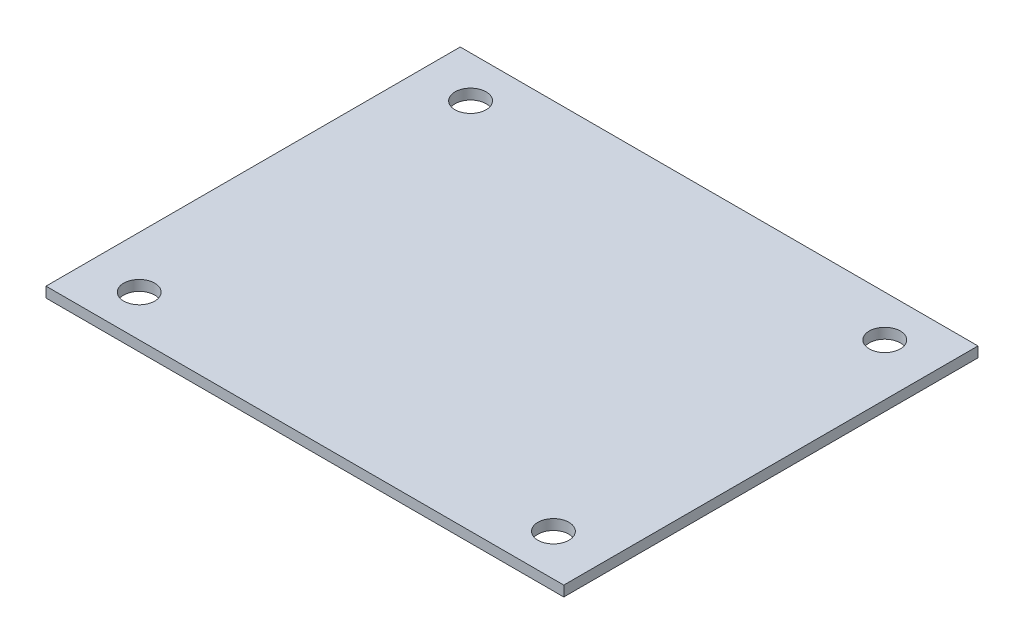
from build123d import *

# Parameters (mm, degrees)
SKETCH1_W           = 50
SKETCH1_H           = 40
SKETCH1_R           = 1.5
BOSS_EXTRUDE1_DEPTH = 1


with BuildPart() as part:
    # Sketch1 → Boss-Extrude1 (new body)
    with BuildSketch(Plane(origin=(0, 0, 0), x_dir=(1, 0, 0), z_dir=(0, 1, 0))):
        Rectangle(SKETCH1_W, SKETCH1_H)
        with Locations((-20, -16)):
            Circle(SKETCH1_R, mode=Mode.SUBTRACT)
        with Locations((-20, 16)):
            Circle(SKETCH1_R, mode=Mode.SUBTRACT)
        with Locations((20, -16)):
            Circle(SKETCH1_R, mode=Mode.SUBTRACT)
        with Locations((20, 16)):
            Circle(SKETCH1_R, mode=Mode.SUBTRACT)
    extrude(amount=BOSS_EXTRUDE1_DEPTH)


solid = part.part
